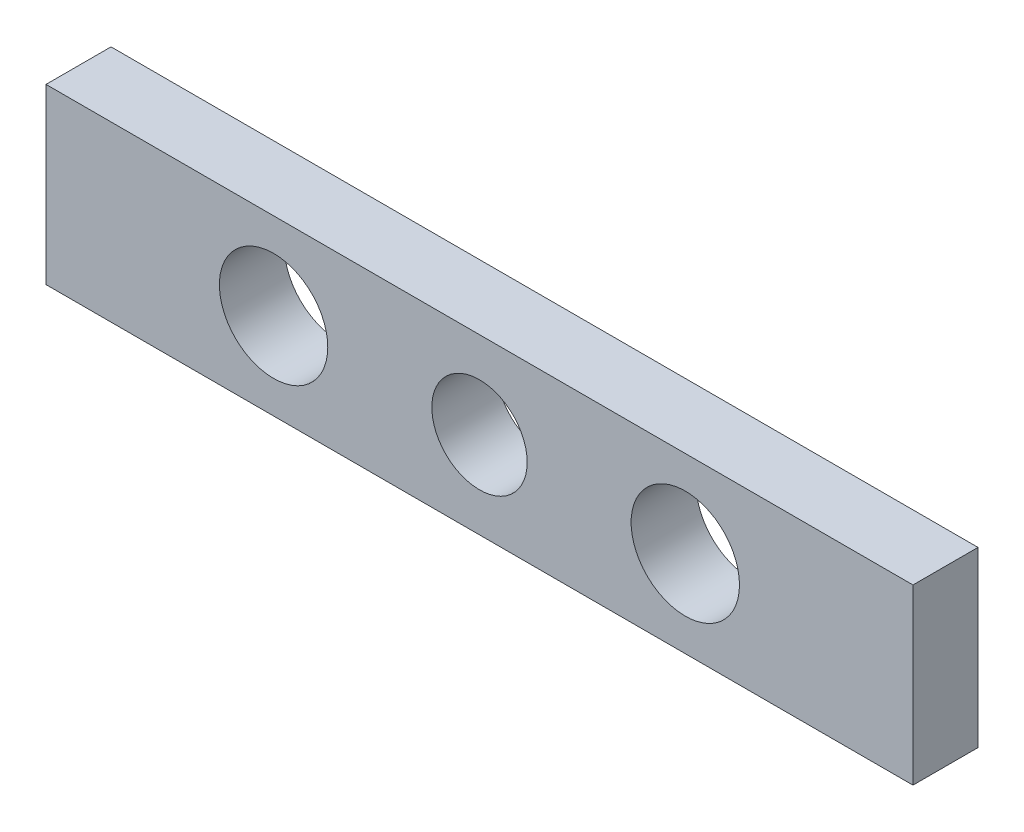
from build123d import *

# Parameters (mm, degrees)
SKETCH1_W           = 40
SKETCH1_H           = 8
SKETCH1_R           = 2.2
BOSS_EXTRUDE1_DEPTH = 3


with BuildPart() as part:
    # Sketch1 → Boss-Extrude1 (new body)
    with BuildSketch(Plane.XY):
        with Locations((0.002263133, 1)):
            Rectangle(SKETCH1_W, SKETCH1_H)
        with Locations((0.002263133, 1)):
            Circle(SKETCH1_R, mode=Mode.SUBTRACT)
        with BuildLine():
            ThreePointArc((-11.98520546, 1.25), (-11.997736867, 1), (-11.98520546, 0.75))
            ThreePointArc((-11.98520546, 0.75), (-6.997736867, 1), (-11.98520546, 1.25))
        make_face(mode=Mode.SUBTRACT)
        with BuildLine():
            ThreePointArc((11.98520546, 1.25), (6.997736867, 1), (11.98520546, 0.75))
            ThreePointArc((11.98520546, 0.75), (11.997736867, 1), (11.98520546, 1.25))
        make_face(mode=Mode.SUBTRACT)
    extrude(amount=BOSS_EXTRUDE1_DEPTH)


solid = part.part
